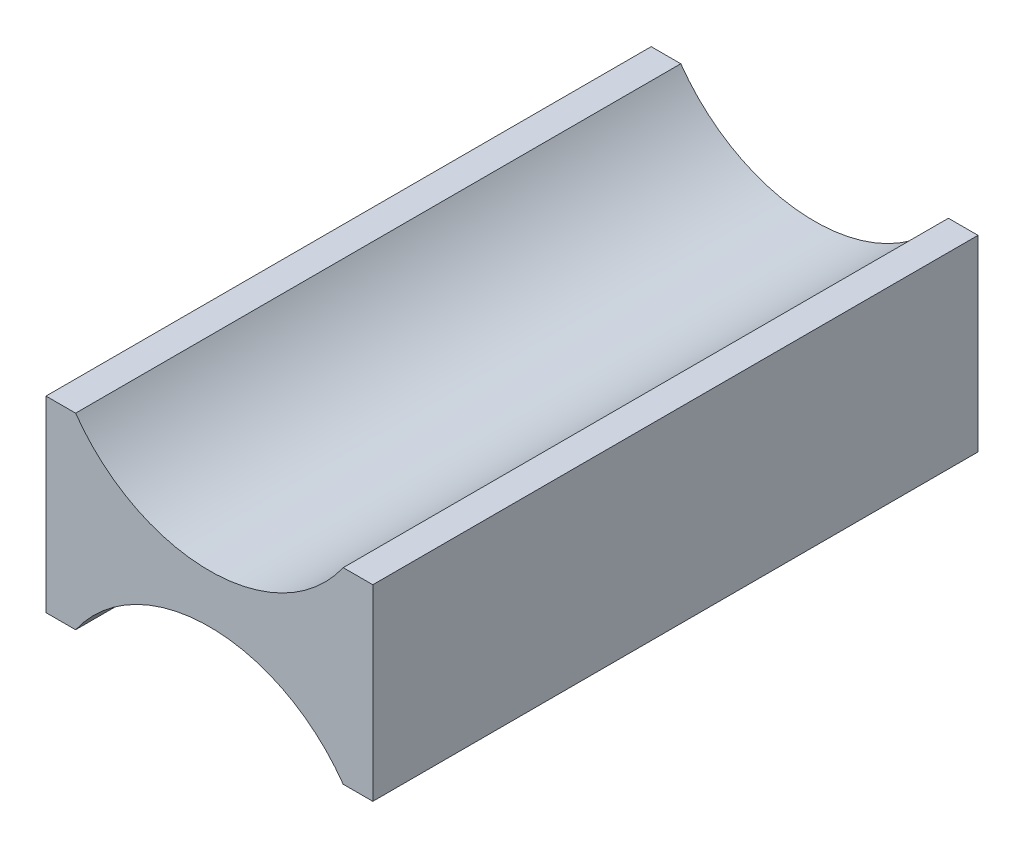
from build123d import *

# Parameters (mm, degrees)
BOSS_EXTRU_1_DEPTH = 10


with BuildPart() as part:
    # Esquisse1 → Boss.-Extru.1 (new body)
    with BuildSketch(Plane.XY):
        with BuildLine():
            Line((-2.7, 1.55), (-2.7, -1.55))
            Line((-2.7, -1.55), (-2.210769097, -1.55))
            ThreePointArc((-2.210769097, -1.55), (0, -0.4), (2.210769097, -1.55))
            Line((2.210769097, -1.55), (2.7, -1.55))
            Line((2.7, -1.55), (2.7, 1.55))
            Line((2.7, 1.55), (2.210769097, 1.55))
            ThreePointArc((2.210769097, 1.55), (0, 0.4), (-2.210769097, 1.55))
            Line((-2.210769097, 1.55), (-2.7, 1.55))
        make_face()
    extrude(amount=BOSS_EXTRU_1_DEPTH)


solid = part.part
